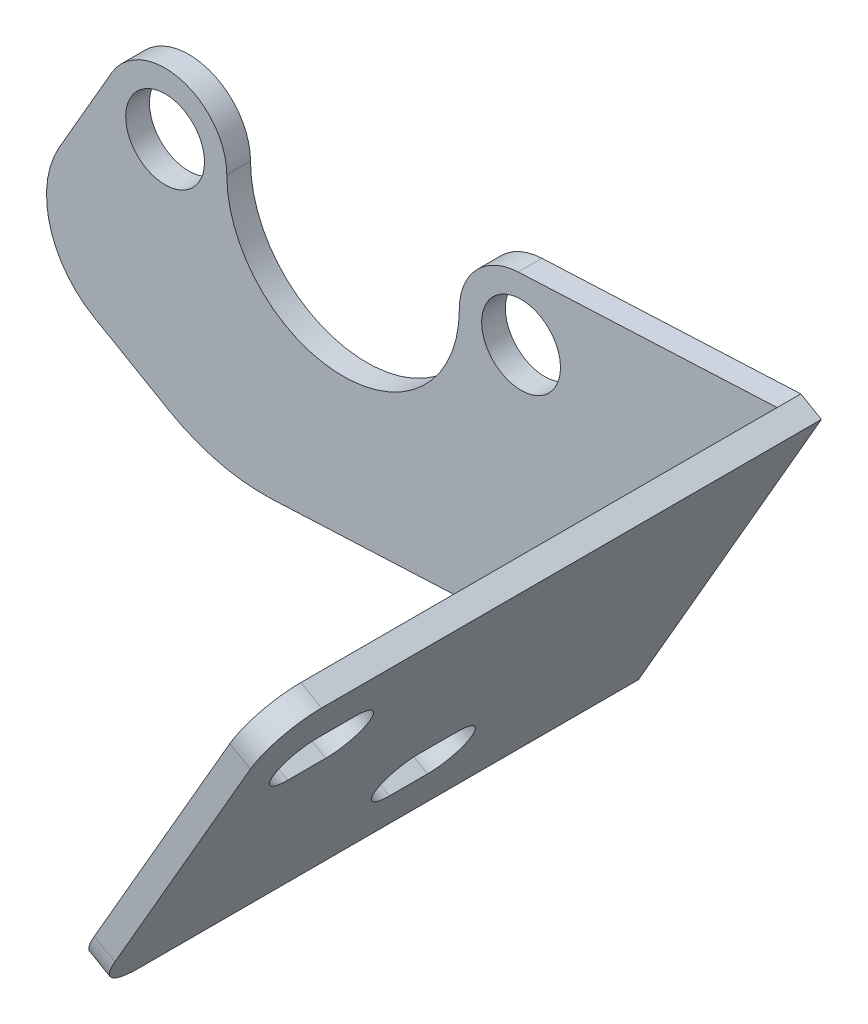
from build123d import *

# Parameters (mm, degrees)
SKETCH3_R           = 5.2705
BOSS_EXTRUDE1_DEPTH = 3.175
BOSS_EXTRUDE2_DEPTH = 70.05
FILLET1_R           = 12.7
FILLET3_R           = 25.4
SKETCH5_R           = 3.96875
CUT_EXTRUDE1_DEPTH  = 6.35
FILLET4_R           = 6.35


with BuildPart() as part:
    # Sketch3 → Boss-Extrude1 (new body)
    with BuildSketch(Plane.XY):
        with BuildLine():
            Line((-31.875, 1.314467847), (-31.875, 2.123689729))
            Line((-31.875, 2.123689729), (-44.309751158, -19.413931056))
            Line((-44.309751158, -19.413931056), (-16.813444588, -35.288931056))
            Line((-16.813444588, -35.288931056), (33.603324087, -32.943986013))
            Line((33.603324087, -32.943986013), (36.352954744, -34.531486013))
            Line((36.352954744, -34.531486013), (60.833371586, 7.869839748))
            Line((60.833371586, 7.869839748), (58.083740929, 9.457339748))
            Line((58.083740929, 9.457339748), (23.441464566, 7.84608547))
            ThreePointArc((23.441464566, 7.84608547), (28.824079828, 6.169187612), (31.875, 1.428257367))
            ThreePointArc((31.875, 1.428257367), (32.028589915, 0.519857326), (32.08, -0.4))
            ThreePointArc((32.08, -0.4), (32.028589915, -1.319857326), (31.875, -2.228257367))
            Line((31.875, -2.228257367), (31.875, -6.284053394))
            ThreePointArc((31.875, -6.284053394), (21.132205448, -10.12115273), (9.948783703, -12.371051434))
            ThreePointArc((9.948783703, -12.371051434), (0.015428746, -15.957499724), (-9.919275826, -12.374791656))
            ThreePointArc((-9.919275826, -12.374791656), (-21.117875037, -10.125129582), (-31.875, -6.284053394))
            Line((-31.875, -6.284053394), (-31.875, -2.114467847))
            ThreePointArc((-31.875, -2.114467847), (-32.055, -0.4), (-31.875, 1.314467847))
        make_face()
        with BuildLine():
            ThreePointArc((15.57, -0.4), (14.094750174, -7.012566542), (9.948783703, -12.371051434))
            ThreePointArc((9.948783703, -12.371051434), (21.132205448, -10.12115273), (31.875, -6.284053394))
            Line((31.875, -6.284053394), (31.875, -2.228257367))
            ThreePointArc((31.875, -2.228257367), (22.905142674, -8.603589915), (15.57, -0.4))
        make_face()
        with BuildLine():
            ThreePointArc((23.441464566, 7.84608547), (17.853772739, 5.299953508), (15.57, -0.4))
            ThreePointArc((15.57, -0.4), (22.905142674, -8.603589915), (31.875, -2.228257367))
            Line((31.875, -2.228257367), (31.875, 1.428257367))
            ThreePointArc((31.875, 1.428257367), (28.824079828, 6.169187612), (23.441464566, 7.84608547))
        make_face()
        with Locations((23.825, -0.4)):
            Circle(SKETCH3_R, mode=Mode.SUBTRACT)
        with BuildLine():
            ThreePointArc((-9.919275826, -12.374791656), (-14.068505089, -7.015217451), (-15.545, -0.4))
            ThreePointArc((-15.545, -0.4), (-22.938054526, -8.609876674), (-31.875, -2.114467847))
            Line((-31.875, -2.114467847), (-31.875, -6.284053394))
            ThreePointArc((-31.875, -6.284053394), (-21.117875037, -10.125129582), (-9.919275826, -12.374791656))
        make_face()
        with BuildLine():
            ThreePointArc((-15.545, -0.4), (-21.663448783, 7.573717696), (-30.949039708, 3.7275))
            ThreePointArc((-30.949039708, 3.7275), (-31.507044005, 2.557447835), (-31.875, 1.314467847))
            Line((-31.875, 1.314467847), (-31.875, -2.114467847))
            ThreePointArc((-31.875, -2.114467847), (-22.938054526, -8.609876674), (-15.545, -0.4))
        make_face()
        with Locations((-23.8, -0.4)):
            Circle(SKETCH3_R, mode=Mode.SUBTRACT)
        with BuildLine():
            Line((31.875, 1.428257367), (31.875, -2.228257367))
            ThreePointArc((31.875, -2.228257367), (32.028589915, -1.319857326), (32.08, -0.4))
            ThreePointArc((32.08, -0.4), (32.028589915, 0.519857326), (31.875, 1.428257367))
        make_face()
        with BuildLine():
            Line((-31.875, -2.114467847), (-31.875, 1.314467847))
            ThreePointArc((-31.875, 1.314467847), (-32.055, -0.4), (-31.875, -2.114467847))
        make_face()
        with BuildLine():
            ThreePointArc((-31.875, 1.314467847), (-31.507044005, 2.557447835), (-30.949039708, 3.7275))
            Line((-30.949039708, 3.7275), (-31.875, 2.123689729))
            Line((-31.875, 2.123689729), (-31.875, 1.314467847))
        make_face()
    extrude(amount=BOSS_EXTRUDE1_DEPTH)

    # Sketch4 → Boss-Extrude2 (add)
    with BuildSketch(Plane.XY.offset(3.175)):
        Polygon((60.833371586, 7.869839748), (36.352954744, -34.531486013), (33.603324087, -32.943986013), (58.083740929, 9.457339748), align=None)
    extrude(amount=BOSS_EXTRUDE2_DEPTH)

    # Fillet1
    fillet1_edges = [part.edges().sort_by_distance(p)[0] for p in [
        (-44.309751158, -19.413931056, 1.5875),
    ]]
    fillet(fillet1_edges, radius=FILLET1_R)

    # Fillet3
    fillet3_edges = [part.edges().sort_by_distance(p)[0] for p in [
        (-16.813444588, -35.288931056, 1.5875),
    ]]
    fillet(fillet3_edges, radius=FILLET3_R)

    # Sketch5 → Cut-Extrude1 (cut)
    with BuildSketch(Plane(origin=(39.46765746, -22.786662659, 0), x_dir=(0, 0, 1), z_dir=(-0.866025404, 0.5, 0))):
        with Locations((63.065, 24.532166939)):
            Circle(SKETCH5_R)
        with Locations((57.985, 24.532166939)):
            Circle(SKETCH5_R)
        with BuildLine():
            ThreePointArc((60.525, 21.482679021), (59.335614932, 20.800302007), (57.985, 20.563416939))
            Line((57.985, 20.563416939), (63.065, 20.563416939))
            ThreePointArc((63.065, 20.563416939), (61.714385068, 20.800302007), (60.525, 21.482679021))
        make_face()
        with BuildLine():
            Line((63.065, 28.500916939), (57.985, 28.500916939))
            ThreePointArc((57.985, 28.500916939), (59.335614932, 28.26403187), (60.525, 27.581654857))
            ThreePointArc((60.525, 27.581654857), (61.714385068, 28.26403187), (63.065, 28.500916939))
        make_face()
        with Locations((37.665, 0.971333254)):
            Circle(SKETCH5_R)
        with Locations((32.585, 0.971333254)):
            Circle(SKETCH5_R)
        with BuildLine():
            Line((37.665, 4.940083254), (32.585, 4.940083254))
            ThreePointArc((32.585, 4.940083254), (33.935614932, 4.703198186), (35.125, 4.020821172))
            ThreePointArc((35.125, 4.020821172), (36.314385068, 4.703198186), (37.665, 4.940083254))
        make_face()
        with BuildLine():
            ThreePointArc((35.125, -2.078154664), (33.935614932, -2.760531678), (32.585, -2.997416746))
            Line((32.585, -2.997416746), (37.665, -2.997416746))
            ThreePointArc((37.665, -2.997416746), (36.314385068, -2.760531678), (35.125, -2.078154664))
        make_face()
    extrude(amount=-CUT_EXTRUDE1_DEPTH, mode=Mode.SUBTRACT)

    # Fillet4
    fillet4_edges = [part.edges().sort_by_distance(p)[0] for p in [
        (34.978139415, -33.737736013, 73.225),
        (59.458556258, 8.663589748, 73.225),
    ]]
    fillet(fillet4_edges, radius=FILLET4_R)


solid = part.part
